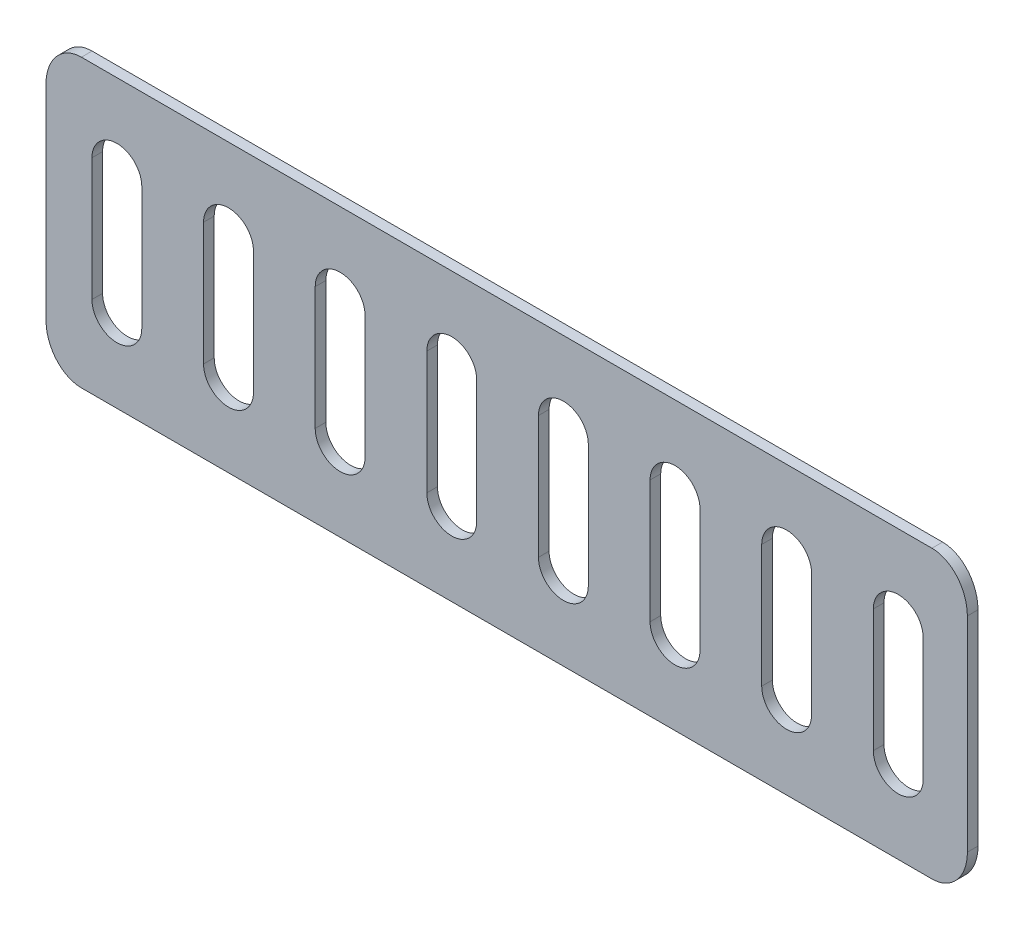
from build123d import *

# Parameters (mm, degrees)
BOSS_EXTRUDE1_DEPTH = 3


with BuildPart() as part:
    # Sketch1 → Boss-Extrude1 (new body)
    with BuildSketch(Plane.XY):
        with BuildLine():
            Line((120, 80.829037687), (-120, 80.829037687))
            add(Edge.make_bspline(
                [(-130, 92.37604307), (-130, 80.829037687), (-120, 80.829037687)],
                knots=[1.570796327, 1.570796327, 1.570796327, 3.141592654, 3.141592654, 3.141592654], degree=2, weights=[1, 0.707106781, 1]))
            Line((-130, 92.37604307), (-130, 150.111069989))
            add(Edge.make_bspline(
                [(-120, 161.658075373), (-130, 161.658075373), (-130, 150.111069989)],
                knots=[0, 0, 0, 1.570796327, 1.570796327, 1.570796327], degree=2, weights=[1, 0.707106781, 1]))
            Line((-120, 161.658075373), (120, 161.658075373))
            add(Edge.make_bspline(
                [(130, 150.111069989), (130, 161.658075373), (120, 161.658075373)],
                knots=[4.71238898, 4.71238898, 4.71238898, 6.283185307, 6.283185307, 6.283185307], degree=2, weights=[1, 0.707106781, 1]))
            Line((130, 150.111069989), (130, 92.37604307))
            add(Edge.make_bspline(
                [(120, 80.829037687), (130, 80.829037687), (130, 92.37604307)],
                knots=[3.141592654, 3.141592654, 3.141592654, 4.71238898, 4.71238898, 4.71238898], degree=2, weights=[1, 0.707106781, 1]))
        make_face()
        with BuildLine():
            Line((-102.965755224, 138.564064606), (-102.965755224, 103.923048454))
            ThreePointArc((-102.965755224, 103.923048454), (-110, 96.888803678), (-117.034244776, 103.923048454))
            Line((-117.034244776, 103.923048454), (-117.034244776, 138.564064606))
            ThreePointArc((-117.034244776, 138.564064606), (-110, 145.598309381), (-102.965755224, 138.564064606))
        make_face(mode=Mode.SUBTRACT)
        with BuildLine():
            Line((-85.534244776, 138.564064606), (-85.534244776, 103.923048454))
            ThreePointArc((-85.534244776, 103.923048454), (-78.5, 96.888803678), (-71.465755224, 103.923048454))
            Line((-71.465755224, 103.923048454), (-71.465755224, 138.564064606))
            ThreePointArc((-71.465755224, 138.564064606), (-78.5, 145.598309381), (-85.534244776, 138.564064606))
        make_face(mode=Mode.SUBTRACT)
        with BuildLine():
            Line((-54.034244776, 138.564064606), (-54.034244776, 103.923048454))
            ThreePointArc((-54.034244776, 103.923048454), (-47, 96.888803678), (-39.965755224, 103.923048454))
            Line((-39.965755224, 103.923048454), (-39.965755224, 138.564064606))
            ThreePointArc((-39.965755224, 138.564064606), (-47, 145.598309381), (-54.034244776, 138.564064606))
        make_face(mode=Mode.SUBTRACT)
        with BuildLine():
            Line((-22.534244776, 138.564064606), (-22.534244776, 103.923048454))
            ThreePointArc((-22.534244776, 103.923048454), (-15.5, 96.888803678), (-8.465755224, 103.923048454))
            Line((-8.465755224, 103.923048454), (-8.465755224, 138.564064606))
            ThreePointArc((-8.465755224, 138.564064606), (-15.5, 145.598309381), (-22.534244776, 138.564064606))
        make_face(mode=Mode.SUBTRACT)
        with BuildLine():
            Line((8.965755224, 138.564064606), (8.965755224, 103.923048454))
            ThreePointArc((8.965755224, 103.923048454), (16, 96.888803678), (23.034244776, 103.923048454))
            Line((23.034244776, 103.923048454), (23.034244776, 138.564064606))
            ThreePointArc((23.034244776, 138.564064606), (16, 145.598309381), (8.965755224, 138.564064606))
        make_face(mode=Mode.SUBTRACT)
        with BuildLine():
            Line((40.465755224, 138.564064606), (40.465755224, 103.923048454))
            ThreePointArc((40.465755224, 103.923048454), (47.5, 96.888803678), (54.534244776, 103.923048454))
            Line((54.534244776, 103.923048454), (54.534244776, 138.564064606))
            ThreePointArc((54.534244776, 138.564064606), (47.5, 145.598309381), (40.465755224, 138.564064606))
        make_face(mode=Mode.SUBTRACT)
        with BuildLine():
            Line((71.965755224, 138.564064606), (71.965755224, 103.923048454))
            ThreePointArc((71.965755224, 103.923048454), (79, 96.888803678), (86.034244776, 103.923048454))
            Line((86.034244776, 103.923048454), (86.034244776, 138.564064606))
            ThreePointArc((86.034244776, 138.564064606), (79, 145.598309381), (71.965755224, 138.564064606))
        make_face(mode=Mode.SUBTRACT)
        with BuildLine():
            Line((103.465755224, 138.564064606), (103.465755224, 103.923048454))
            ThreePointArc((103.465755224, 103.923048454), (110.5, 96.888803678), (117.534244776, 103.923048454))
            Line((117.534244776, 103.923048454), (117.534244776, 138.564064606))
            ThreePointArc((117.534244776, 138.564064606), (110.5, 145.598309381), (103.465755224, 138.564064606))
        make_face(mode=Mode.SUBTRACT)
    extrude(amount=-BOSS_EXTRUDE1_DEPTH)


solid = part.part
